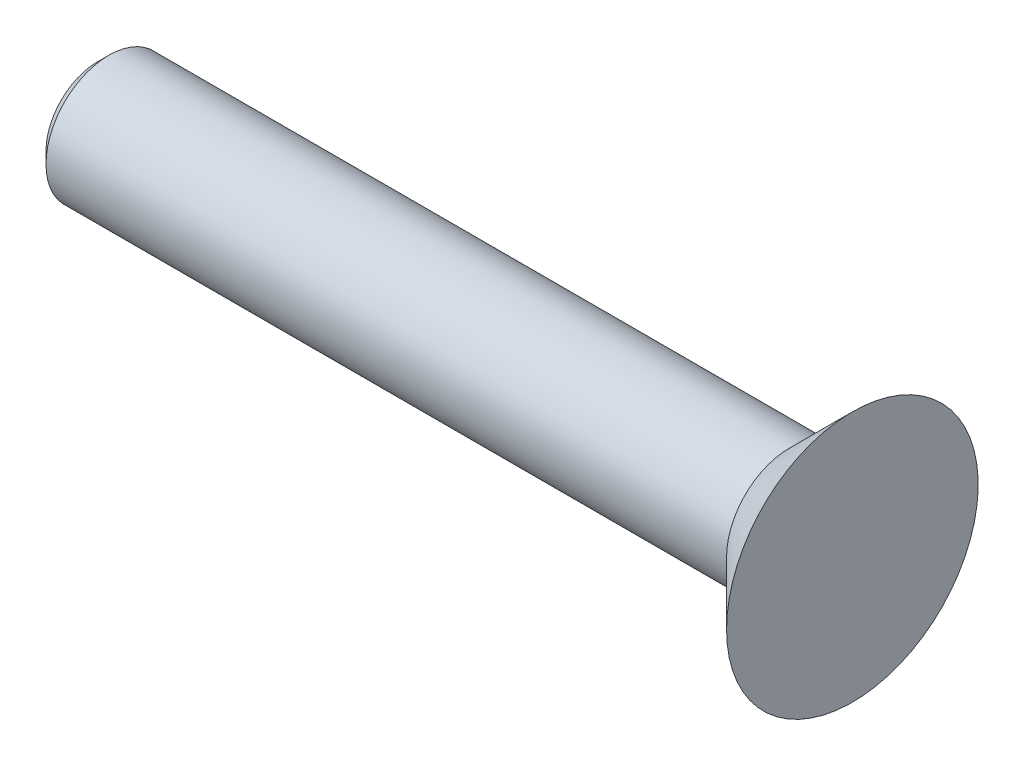
from build123d import *

# Parameters (mm, degrees)
CHANFREIN1_SIZE = 0.225


with BuildPart() as part:
    # Esquisse1 → Révolution1 (revolve)
    with BuildSketch(Plane.XY, mode=Mode.PRIVATE) as r_volution1_sk:
        Polygon((0, 0), (-15, 0), (-15, 1.25), (-1.25, 1.25), (0, 2.5), align=None)
    revolve(r_volution1_sk.sketch.rotate(Axis((0, 0, 0), (1, 0, 0)), 90), axis=Axis((0, 0, 0), (1, 0, 0)))  # turned: the seam where the file's is

    # Chanfrein1
    chanfrein1_edges = [part.edges().sort_by_distance(p)[0] for p in [
        (-15, 0, -1.25),
    ]]
    chamfer(chanfrein1_edges, length=CHANFREIN1_SIZE)


solid = part.part
